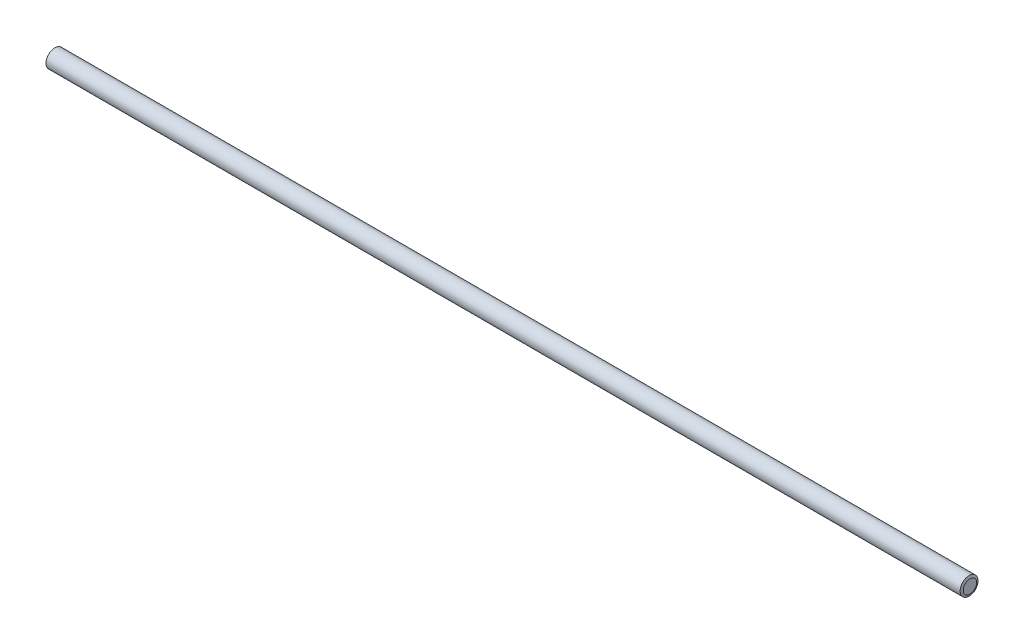
from build123d import *


with BuildPart() as part:
    # Sketch1 → Revolve1 (revolve)
    with BuildSketch(Plane.XY):
        Polygon((0, 0), (0, 3.736946), (0.5, 5), (511.5, 5), (512, 3.736946), (512, 0), align=None)
    revolve(axis=Axis((512, 0, 0), (-1, 0, 0)))


solid = part.part
